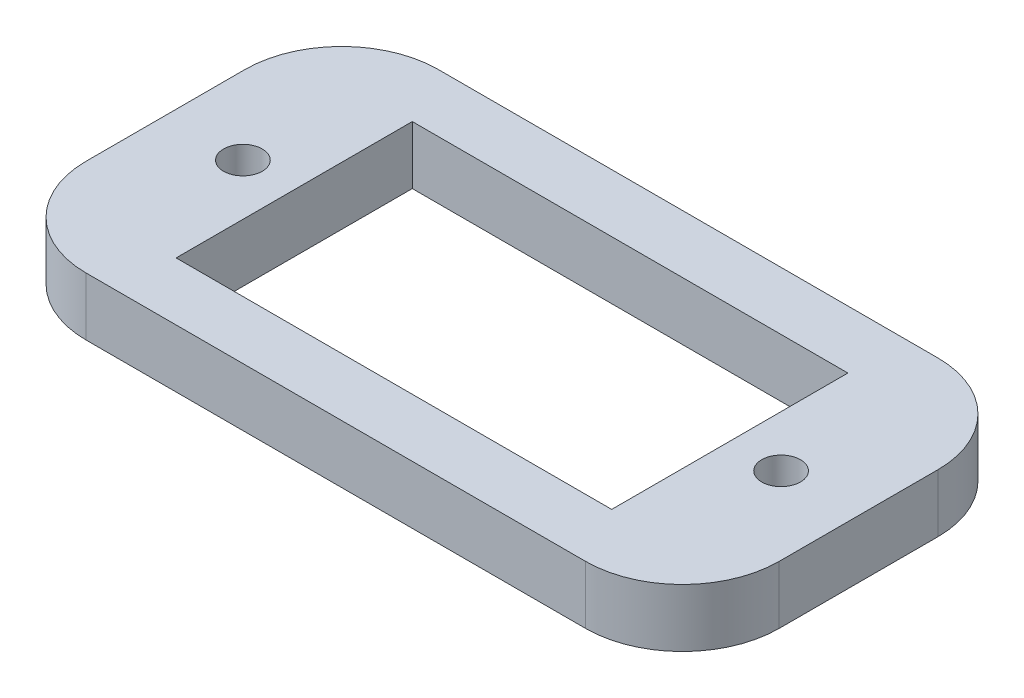
from build123d import *

# Parameters (mm, degrees)
SKETCH1_W           = 35.8
SKETCH1_H           = 18.2
SKETCH1_R           = 1
SKETCH1_W_2         = 22.5
SKETCH1_H_2         = 12.2
BOSS_EXTRUDE1_DEPTH = 1.5
FILLET1_R           = 5


with BuildPart() as part:
    # Sketch1 → Boss-Extrude1 (new body, symmetric)
    with BuildSketch(Plane(origin=(0, 0, 0), x_dir=(1, 0, 0), z_dir=(0, 1, 0))):
        Rectangle(SKETCH1_W, SKETCH1_H)
        with Locations((-13.9, 0)):
            Circle(SKETCH1_R, mode=Mode.SUBTRACT)
        with Locations((13.9, 0)):
            Circle(SKETCH1_R, mode=Mode.SUBTRACT)
        Rectangle(SKETCH1_W_2, SKETCH1_H_2, mode=Mode.SUBTRACT)
    extrude(amount=BOSS_EXTRUDE1_DEPTH, both=True)

    # Fillet1
    fillet1_edges = [part.edges().sort_by_distance(p)[0] for p in [
        (-17.9, 0, -9.1),
        (17.9, 0, -9.1),
        (17.9, 0, 9.1),
        (-17.9, 0, 9.1),
    ]]
    fillet(fillet1_edges, radius=FILLET1_R)


solid = part.part
